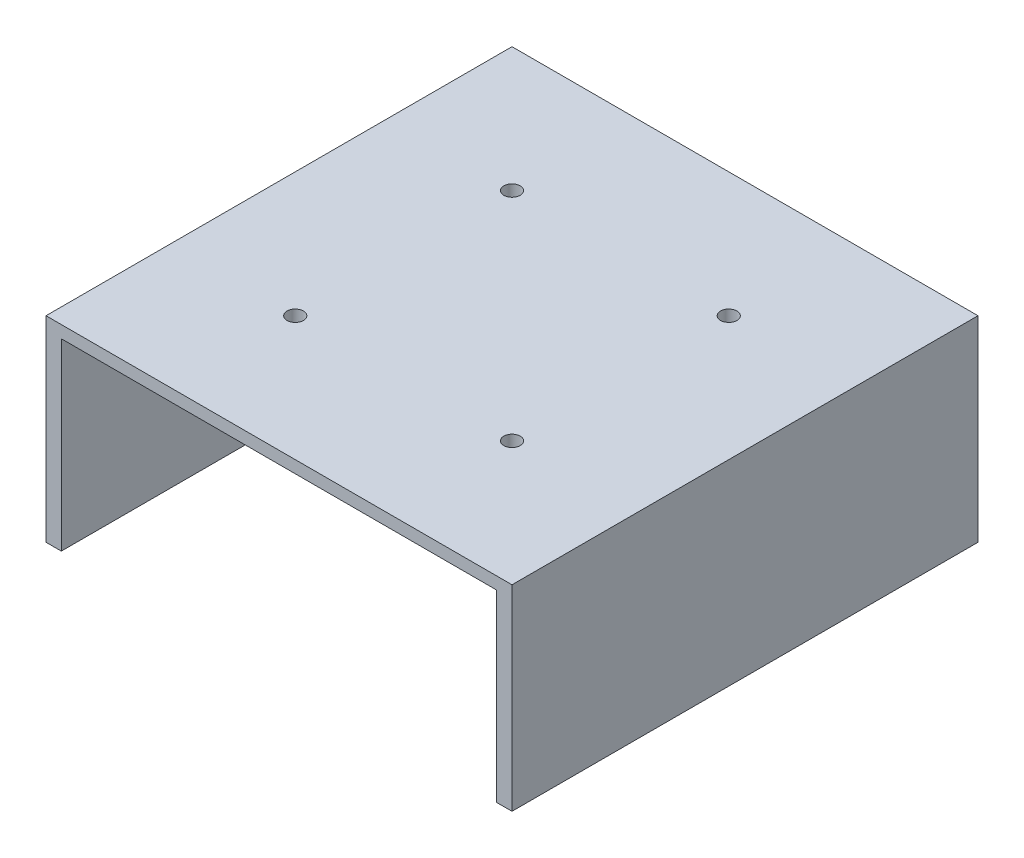
from build123d import *

# Parameters (mm, degrees)
SKETCH1_W           = 96.52
SKETCH1_H           = 96.52
SKETCH1_R           = 1.7
BOSS_EXTRUDE1_DEPTH = 2.54
SKETCH2_W           = 3.175
SKETCH2_H           = 96.52
BOSS_EXTRUDE2_DEPTH = 38.1


with BuildPart() as part:
    # Sketch1 → Boss-Extrude1 (new body)
    with BuildSketch(Plane(origin=(0, 0, 0), x_dir=(1, 0, 0), z_dir=(0, 1, 0))):
        Rectangle(SKETCH1_W, SKETCH1_H)
        with Locations((-22.447883068, 22.447883068)):
            Circle(SKETCH1_R, mode=Mode.SUBTRACT)
        with Locations((22.447883068, 22.447883068)):
            Circle(SKETCH1_R, mode=Mode.SUBTRACT)
        with Locations((22.447883068, -22.447883068)):
            Circle(SKETCH1_R, mode=Mode.SUBTRACT)
        with Locations((-22.447883068, -22.447883068)):
            Circle(SKETCH1_R, mode=Mode.SUBTRACT)
    extrude(amount=BOSS_EXTRUDE1_DEPTH)

    # Sketch2 → Boss-Extrude2 (add)
    with BuildSketch(Plane.XZ):
        with Locations((-46.6725, 0)):
            Rectangle(SKETCH2_W, SKETCH2_H)
        with Locations((46.6725, 0)):
            Rectangle(SKETCH2_W, SKETCH2_H)
    extrude(amount=BOSS_EXTRUDE2_DEPTH)


solid = part.part
